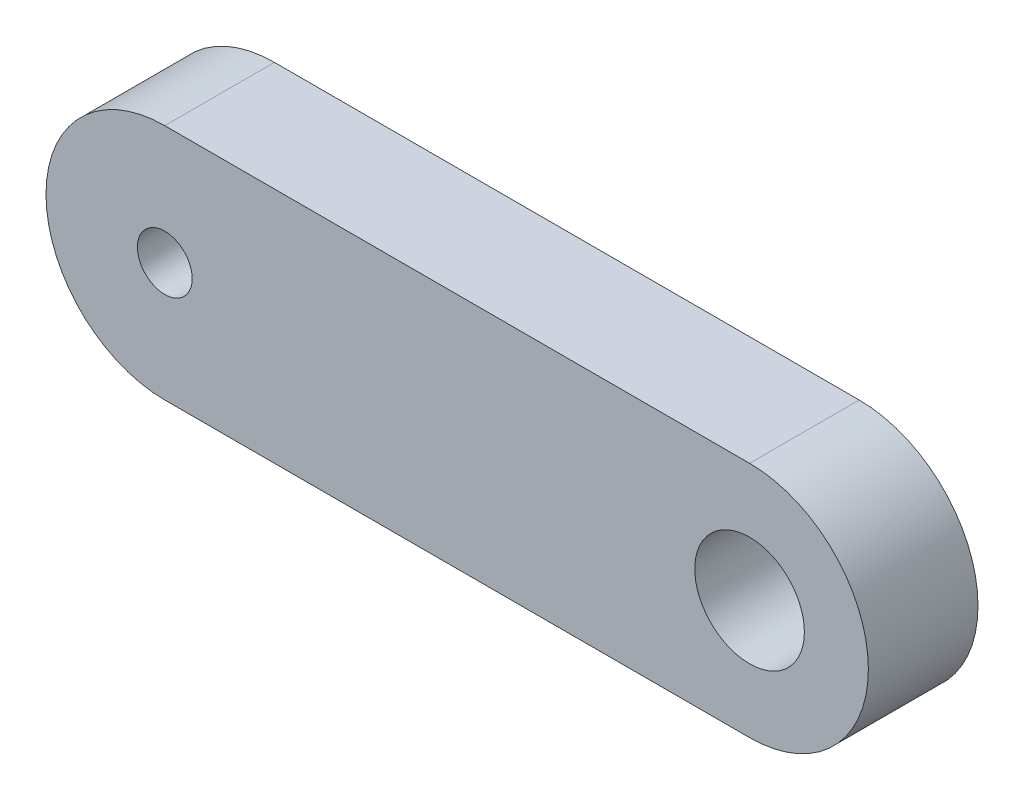
from build123d import *

# Parameters (mm, degrees)
SKETCH1_R           = 0.75
SKETCH1_R_2         = 1.5
BOSS_EXTRUDE1_DEPTH = 1.5


with BuildPart() as part:
    # Sketch1 → Boss-Extrude1 (new body, symmetric)
    with BuildSketch(Plane.XY):
        with BuildLine():
            Line((-8, 3.25), (8, 3.25))
            ThreePointArc((8, 3.25), (11.25, 0), (8, -3.25))
            Line((8, -3.25), (-8, -3.25))
            ThreePointArc((-8, -3.25), (-11.25, 0), (-8, 3.25))
        make_face()
        with Locations((-8, 0)):
            Circle(SKETCH1_R, mode=Mode.SUBTRACT)
        with Locations((8, 0)):
            Circle(SKETCH1_R_2, mode=Mode.SUBTRACT)
    extrude(amount=BOSS_EXTRUDE1_DEPTH, both=True)


solid = part.part
